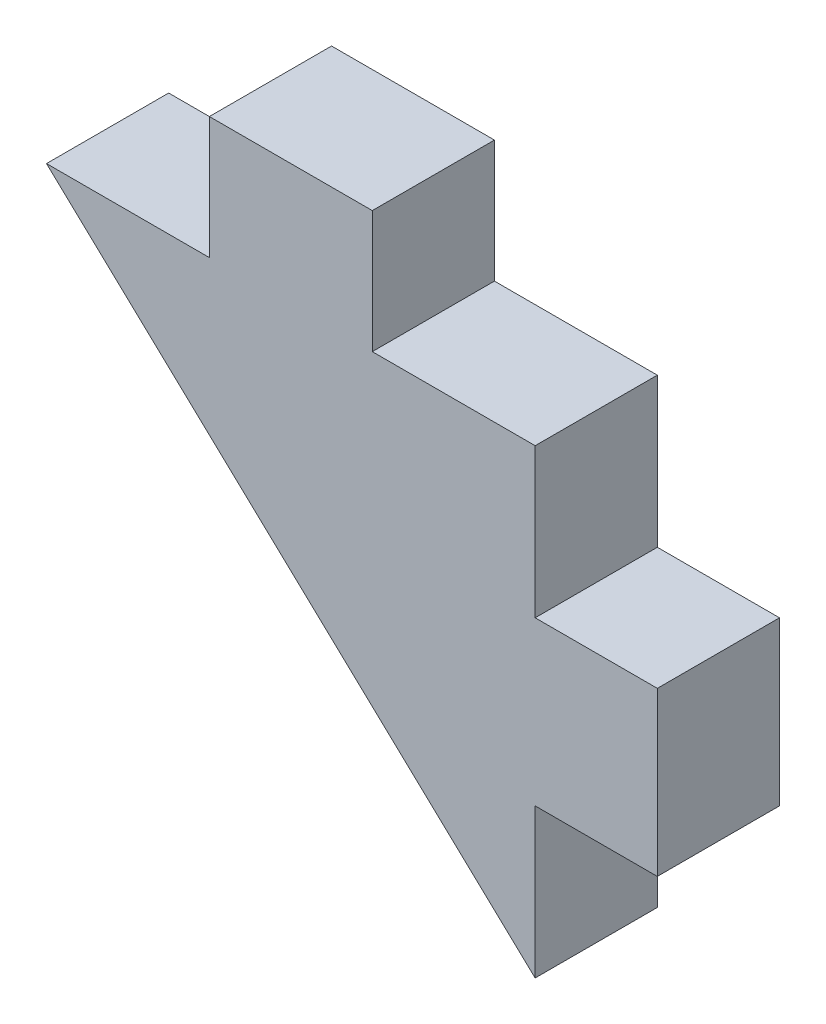
from build123d import *

# Parameters (mm, degrees)
BOSS_EXTRUDE1_DEPTH = 5


with BuildPart() as part:
    # Sketch1 → Boss-Extrude1 (new body)
    with BuildSketch(Plane.XY):
        Polygon((-10, 9.433962264), (10, -9.433962264), (10, -3.333333333), (15, -3.333333333), (15, 3.333333333), (10, 3.333333333), (10, 9.433962264), (3.333333333, 9.433962264), (3.333333333, 14.433962264), (-3.333333333, 14.433962264), (-3.333333333, 9.433962264), align=None)
    extrude(amount=BOSS_EXTRUDE1_DEPTH)


solid = part.part
